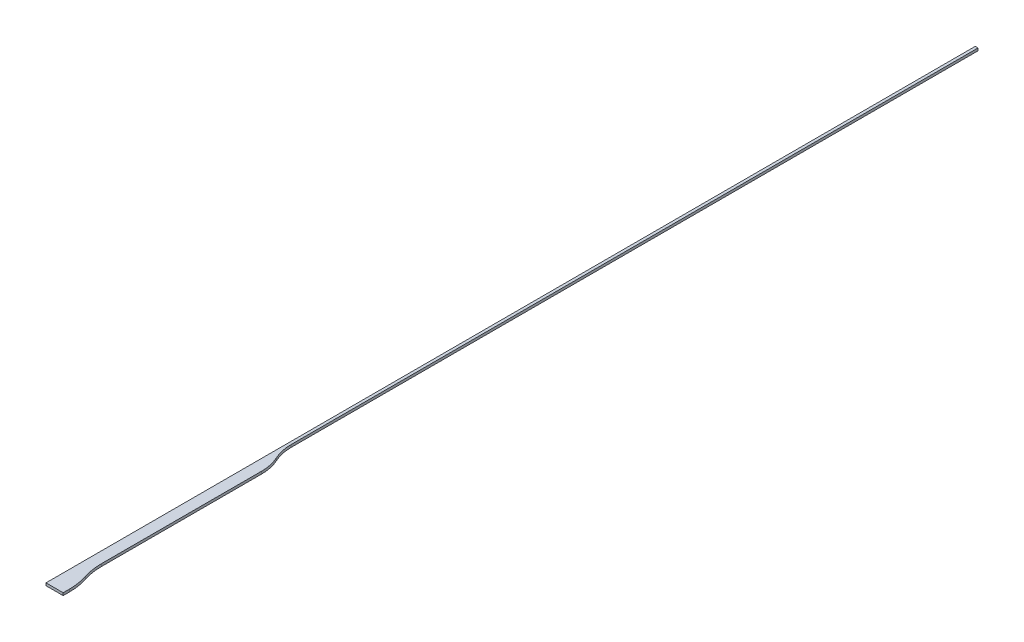
from build123d import *

# Parameters (mm, degrees)
EXTRUDE_THIN1_DEPTH = 5
EXTRUDE1_DEPTH      = 10


with BuildPart() as part:
    # Sketch1 → Extrude-Thin1 (new body, symmetric)
    with BuildSketch(Plane(origin=(0, 0, 0), x_dir=(1, 0, 0), z_dir=(0, 1, 0))):
        with BuildLine():
            Line((-147, 0), (-147, 25))
            ThreePointArc((-147, 25), (-150.018958103, 62.976966704), (-159, 100))
            ThreePointArc((-159, 100), (-167.981041897, 137.023033296), (-171, 175))
            Line((-171, 175), (-171, 810.4))
            ThreePointArc((-171, 810.4), (-175.173739961, 848.796777209), (-187.5, 885.4))
            ThreePointArc((-187.5, 885.4), (-199.826260039, 922.003222791), (-204, 960.4))
            Line((-204, 960.4), (-204, 3680.99975))
            Line((-204, 3680.99975), (-215, 3680.99975))
            Line((-215, 3680.99975), (-215, 960.4))
            ThreePointArc((-215, 960.4), (-210.569349172, 919.639743182), (-197.484357116, 880.783441435))
            ThreePointArc((-197.484357116, 880.783441435), (-185.916829095, 846.433297599), (-182, 810.4))
            Line((-182, 810.4), (-182, 175))
            ThreePointArc((-182, 175), (-178.842888848, 135.285137784), (-169.450858034, 96.567862715))
            ThreePointArc((-169.450858034, 96.567862715), (-160.880805054, 61.239071191), (-158, 25))
            Line((-158, 25), (-158, 0))
            Line((-158, 0), (-147, 0))
        make_face()
    extrude(amount=EXTRUDE_THIN1_DEPTH, both=True)

    # Sketch3 → Extrude1 (add)
    with BuildSketch(Plane(origin=(0, 5, 0), x_dir=(1, 0, 0), z_dir=(0, 1, 0))):
        with BuildLine():
            Line((-158, 0), (-158, 25))
            ThreePointArc((-158, 25), (-160.880805054, 61.239071191), (-169.450858034, 96.567862715))
            ThreePointArc((-169.450858034, 96.567862715), (-178.842888848, 135.285137784), (-182, 175))
            Line((-182, 175), (-182, 810.4))
            ThreePointArc((-182, 810.4), (-185.916829095, 846.433297599), (-197.484357116, 880.783441435))
            ThreePointArc((-197.484357116, 880.783441435), (-210.569349172, 919.639743182), (-215, 960.4))
            Line((-215, 960.4), (-215, 0))
            Line((-215, 0), (-158, 0))
        make_face()
    extrude(amount=-EXTRUDE1_DEPTH)


solid = part.part
